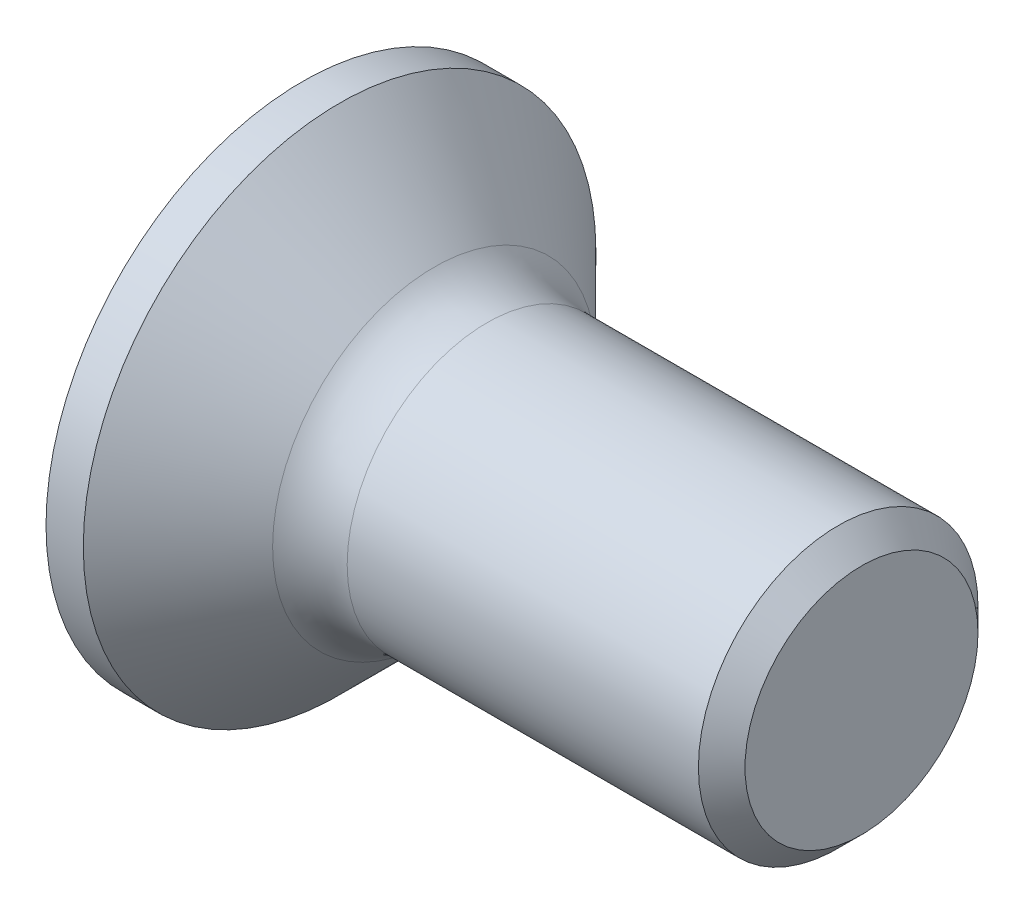
from build123d import *

# Parameters (mm, degrees)
FILLET1_R     = 0.8
SKETCH3_W     = 0.74
SKETCH3_H     = 3
SKETCH4_W     = 0.74
SKETCH4_H     = 0.995702004
RECPAT_COUNT  = 2
RECPAT_ANGLE  = 90
CHANFRO1_SIZE = 0.25


with BuildPart() as part:
    # BodySke → Base-Revolve (revolve)
    with BuildSketch(Plane.XY):
        Polygon((0, 0), (0, 2.75), (0.4, 2.75), (1.65, 1.5), (6, 1.5), (6, 0), align=None)
    revolve(axis=Axis((-6.35, 0, 0), (1, 0, 0)))

    # Fillet1
    fillet1_edges = [part.edges().sort_by_distance(p)[0] for p in [
        (1.65, -1.5, 0),
    ]]
    fillet(fillet1_edges, radius=FILLET1_R)

    # Sketch3 → Recess section 0
    with BuildSketch(Plane.ZY):
        Rectangle(SKETCH3_W, SKETCH3_H)
    # Sketch4 → Recess section 1
    with BuildSketch(Plane.ZY.offset(-2.01)):
        Rectangle(SKETCH4_W, SKETCH4_H)
    recess = loft(mode=Mode.SUBTRACT)

    # RecPat: Recess ×2 about axis
    recpat_axis = Axis((0, 0, 0), (1, 0, 0))
    for i in range(1, RECPAT_COUNT):
        add(recess.rotate(recpat_axis, i * RECPAT_ANGLE / (RECPAT_COUNT - 1)), mode=Mode.SUBTRACT)

    # RecCorSke → RecessCore (revolve, cut)
    with BuildSketch(Plane.XY):
        Polygon((0, 0), (0, 0.696552892), (2.01, 0.556), (2.190655351, 0), align=None)
    revolve(axis=Axis((-3.175, 0, 0), (1, 0, 0)), mode=Mode.SUBTRACT)

    # Chanfro1
    chanfro1_edges = [part.edges().sort_by_distance(p)[0] for p in [
        (6, -1.5, 0),
    ]]
    chamfer(chanfro1_edges, length=CHANFRO1_SIZE)


solid = part.part
